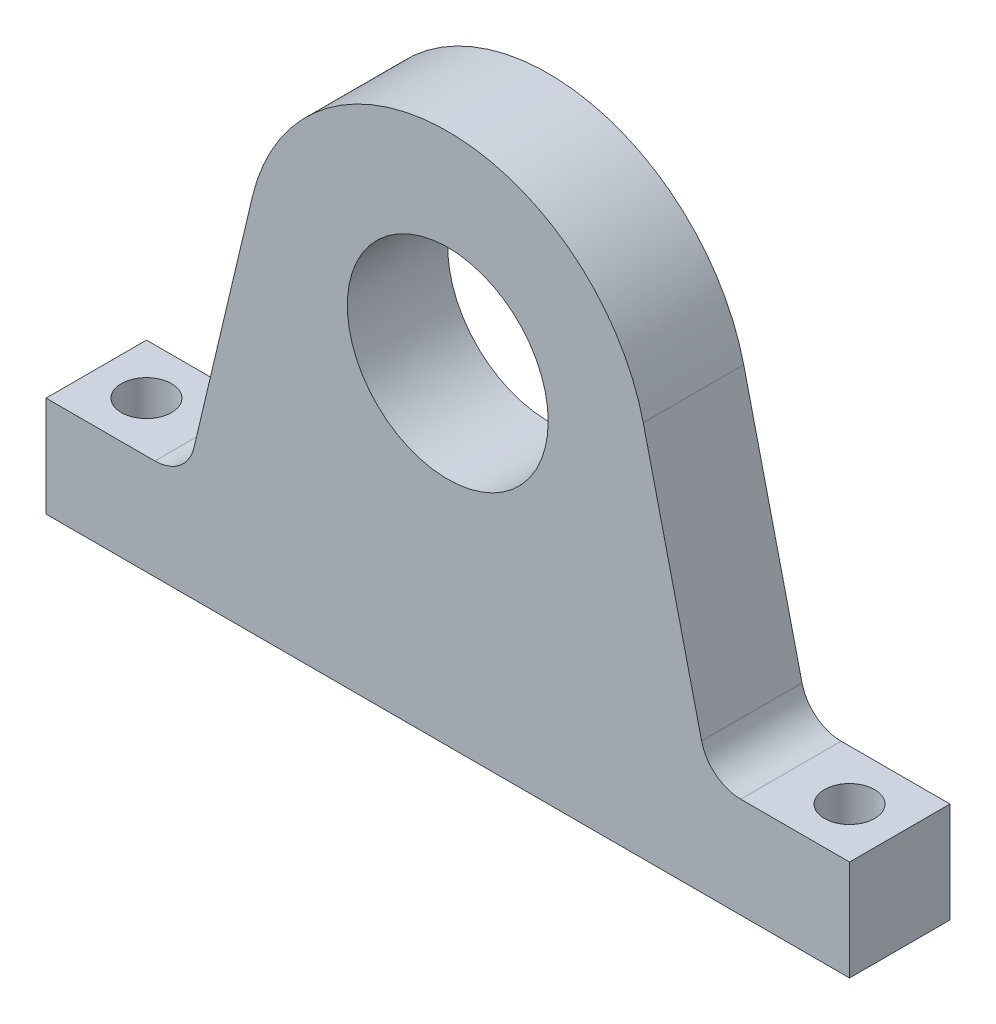
from build123d import *

# Parameters (mm, degrees)
SKETCH1_R           = 12.7
BOSS_EXTRUDE1_DEPTH = 12.7
SKETCH2_R           = 3.175
CUT_EXTRUDE1_DEPTH  = 13.7
FILLET1_R           = 5.08


with BuildPart() as part:
    # Sketch1 → Boss-Extrude1 (new body)
    with BuildSketch(Plane.XY):
        with BuildLine():
            Line((50.8, -41.91), (-50.8, -41.91))
            Line((-50.8, -41.91), (-50.8, -29.21))
            Line((-50.8, -29.21), (-33.02, -29.21))
            Line((-33.02, -29.21), (-24.716371207, 5.853289191))
            ThreePointArc((-24.716371207, 5.853289191), (0, 25.4), (24.716371207, 5.853289191))
            Line((24.716371207, 5.853289191), (33.02, -29.21))
            Line((33.02, -29.21), (50.8, -29.21))
            Line((50.8, -29.21), (50.8, -41.91))
        make_face()
        Circle(SKETCH1_R, mode=Mode.SUBTRACT)
    extrude(amount=BOSS_EXTRUDE1_DEPTH)

    # Sketch2 → Cut-Extrude1 (cut, through all)
    with BuildSketch(Plane(origin=(0, -29.21, 0), x_dir=(1, 0, 0), z_dir=(0, 1, 0))):
        with Locations((-44.45, -6.35)):
            Circle(SKETCH2_R)
        with Locations((44.45, -6.35)):
            Circle(SKETCH2_R)
    extrude(amount=-CUT_EXTRUDE1_DEPTH, mode=Mode.SUBTRACT)

    # Fillet1
    fillet1_edges = [part.edges().sort_by_distance(p)[0] for p in [
        (-33.02, -29.21, 6.35),
        (33.02, -29.21, 6.35),
    ]]
    fillet(fillet1_edges, radius=FILLET1_R)


solid = part.part
